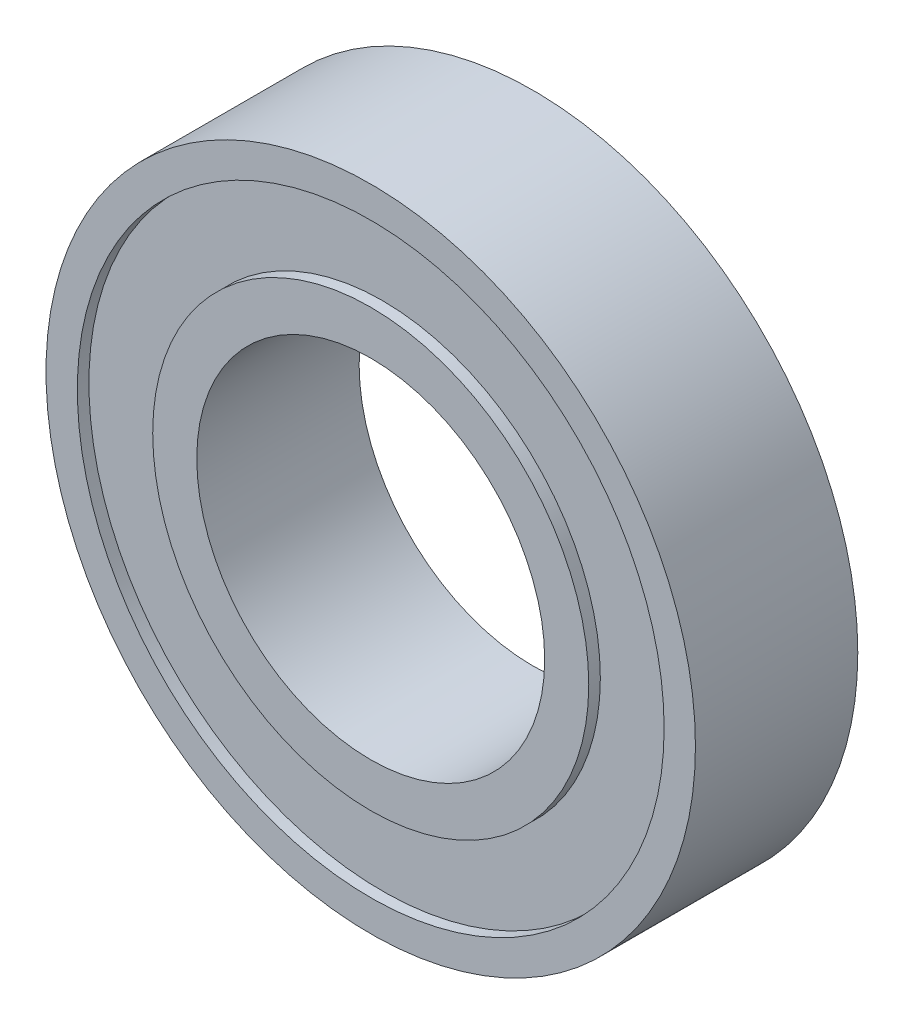
from build123d import *

# Parameters (mm, degrees)
SKETCH_1_R          = 14
EXTRUDE_1_DEPTH     = 7
SKETCH_2_R          = 7.5
CUT_EXTRUDE_1_DEPTH = 8
SKETCH_3_R          = 12.65
SKETCH_3_R_2        = 9.4
CUT_EXTRUDE_2_DEPTH = 0.5
SKETCH_4_R          = 12.65
SKETCH_4_R_2        = 9.4
CUT_EXTRUDE_3_DEPTH = 0.5


with BuildPart() as part:
    # 草圖1 → 填料-伸長1 (new body)
    with BuildSketch(Plane.XY):
        Circle(SKETCH_1_R)
    extrude(amount=EXTRUDE_1_DEPTH)

    # 草圖2 → 除料-伸長1 (cut, through all)
    with BuildSketch(Plane.XY.offset(7)):
        Circle(SKETCH_2_R)
    extrude(amount=-CUT_EXTRUDE_1_DEPTH, mode=Mode.SUBTRACT)

    # 草圖3 → 除料-伸長2 (cut)
    with BuildSketch(Plane.XY.offset(7)):
        Circle(SKETCH_3_R)
        Circle(SKETCH_3_R_2, mode=Mode.SUBTRACT)
    extrude(amount=-CUT_EXTRUDE_2_DEPTH, mode=Mode.SUBTRACT)

    # 草圖4 → 除料-伸長3 (cut)
    with BuildSketch(Plane(origin=(0, 0, 0), x_dir=(-1, 0, 0), z_dir=(0, 0, -1))):
        Circle(SKETCH_4_R)
        Circle(SKETCH_4_R_2, mode=Mode.SUBTRACT)
    extrude(amount=-CUT_EXTRUDE_3_DEPTH, mode=Mode.SUBTRACT)


solid = part.part
